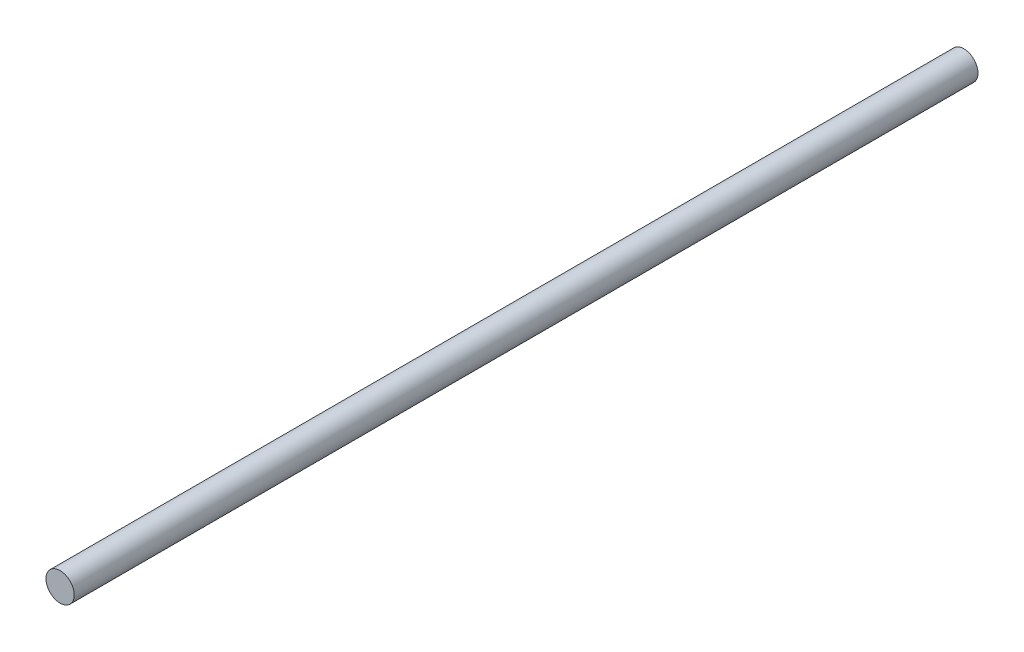
from build123d import *

# Parameters (mm, degrees)
SKETCH1_R           = 6.35
BOSS_EXTRUDE1_DEPTH = 203.2


with BuildPart() as part:
    # Sketch1 → Boss-Extrude1 (new body, symmetric)
    with BuildSketch(Plane.XY):
        Circle(SKETCH1_R)
    extrude(amount=BOSS_EXTRUDE1_DEPTH, both=True)


solid = part.part
